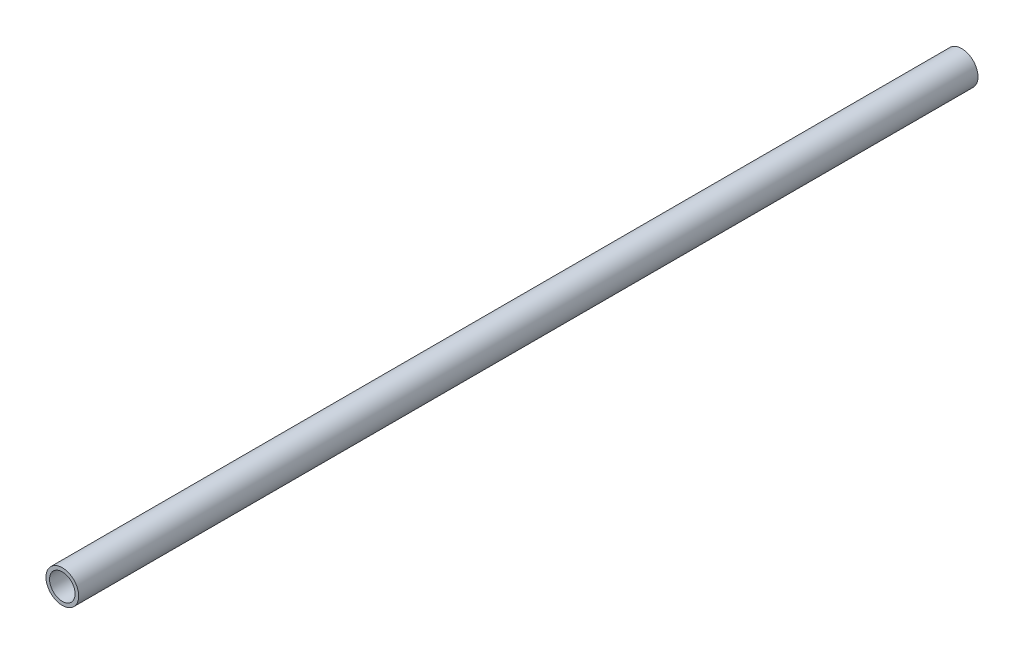
from build123d import *

# Parameters (mm, degrees)
SKETCH1_R           = 4
BOSS_EXTRUDE1_DEPTH = 220
SKETCH2_R           = 3.125
CUT_EXTRUDE1_DEPTH  = 6.5


with BuildPart() as part:
    # Sketch1 → Boss-Extrude1 (new body)
    with BuildSketch(Plane.XY):
        Circle(SKETCH1_R)
    extrude(amount=BOSS_EXTRUDE1_DEPTH)

    # Sketch2 → Cut-Extrude1 (cut)
    with BuildSketch(Plane.XY.offset(220)):
        Circle(SKETCH2_R)
    cut_extrude1 = extrude(amount=-CUT_EXTRUDE1_DEPTH, mode=Mode.SUBTRACT)

    # Mirror1: Cut-Extrude1 across plane
    add(cut_extrude1.mirror(Plane.XY.offset(110)), mode=Mode.SUBTRACT)


solid = part.part
